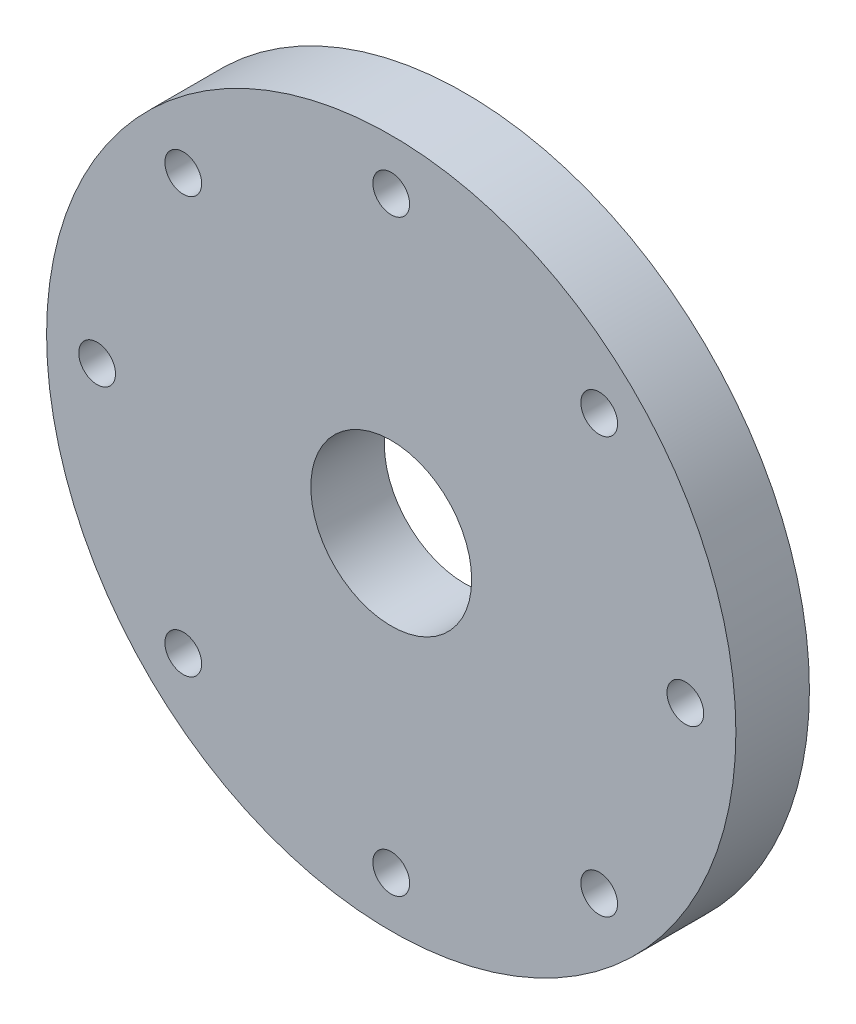
from build123d import *

# Parameters (mm, degrees)
SKETCH1_W                    = 75
SKETCH1_H                    = 16
F_8_0_8_DIAMETER_HOLE1_D     = 8
F_8_0_8_DIAMETER_HOLE1_DEPTH = 30
F_8_0_8_DIAMETER_HOLE1_TIP   = 2.403442476
M6_CLEARANCE_HOLE1_D         = 8
M6_CLEARANCE_HOLE1_DEPTH     = 22
M6_CLEARANCE_HOLE1_TIP       = 2.403442476
SKETCH8_R                    = 17.5
CUT_EXTRUDE1_DEPTH           = 30


with BuildPart() as part:
    # Sketch1 → Revolve1 (revolve)
    with BuildSketch(Plane(origin=(0, 0, 0), x_dir=(1, 0, 0), z_dir=(0, 1, 0))):
        with Locations((37.5, -22)):
            Rectangle(SKETCH1_W, SKETCH1_H)
    revolve(axis=Axis((0, 0, 14), (0, 0, 1)))

    # Ø8.0 (8) Diameter Hole1
    with Locations(Plane(origin=(0, 0, 14), x_dir=(-1, 0, 0), z_dir=(0, 0, -1))):
        with Locations((45.254833996, 45.254833996), (-45.254833996, 45.254833996), (-45.254833996, -45.254833996), (45.254833996, -45.254833996)):
            Hole(F_8_0_8_DIAMETER_HOLE1_D / 2, depth=F_8_0_8_DIAMETER_HOLE1_DEPTH)
            with Locations((0, 0, -(F_8_0_8_DIAMETER_HOLE1_DEPTH + F_8_0_8_DIAMETER_HOLE1_TIP / 2))):  # 118° drill point
                Cone(0, F_8_0_8_DIAMETER_HOLE1_D / 2, F_8_0_8_DIAMETER_HOLE1_TIP, mode=Mode.SUBTRACT)

    # M6 Clearance Hole1
    with Locations(Plane.XY.offset(30)):
        with Locations((0, 64), (0, -64), (64, 0), (-64, 0)):
            Hole(M6_CLEARANCE_HOLE1_D / 2, depth=M6_CLEARANCE_HOLE1_DEPTH)
            with Locations((0, 0, -(M6_CLEARANCE_HOLE1_DEPTH + M6_CLEARANCE_HOLE1_TIP / 2))):  # 118° drill point
                Cone(0, M6_CLEARANCE_HOLE1_D / 2, M6_CLEARANCE_HOLE1_TIP, mode=Mode.SUBTRACT)

    # Sketch8 → Cut-Extrude1 (cut)
    with BuildSketch(Plane.XY.offset(30)):
        Circle(SKETCH8_R)
    extrude(amount=-CUT_EXTRUDE1_DEPTH, mode=Mode.SUBTRACT)


solid = part.part
